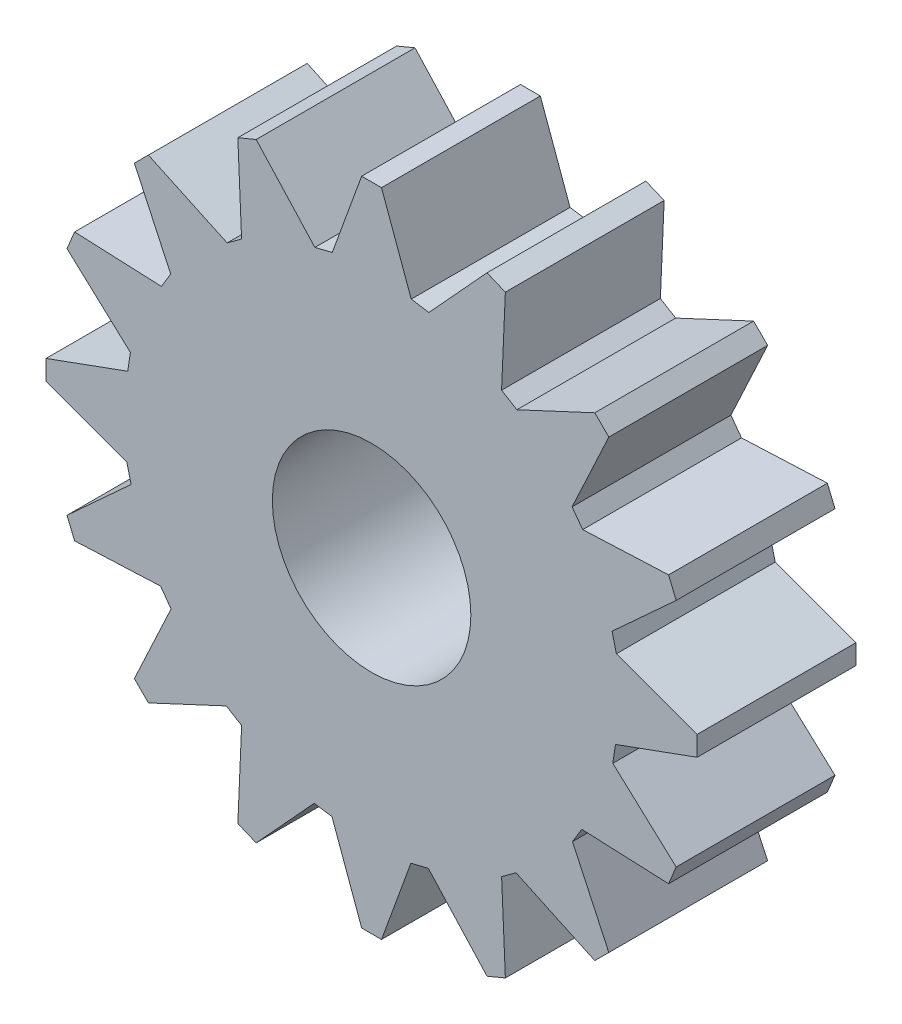
from build123d import *

# Parameters (mm, degrees)
SKETCH_1_R      = 2.5
EXTRUDE_1_DEPTH = 4


with BuildPart() as part:
    # 草图1 → 凸台-拉伸1 (new body)
    with BuildSketch(Plane.XY):
        Polygon((-0.25, 8.2), (0.25, 8.2), (0.998649517, 6.143102356), (1.444411986, 6.075310901), (2.907034262, 7.671483025), (3.368974029, 7.480141309), (3.273495344, 5.293319907), (3.659383499, 5.060102858), (5.62149891, 5.975052301), (5.975052301, 5.62149891), (5.049981179, 3.637677487), (5.317247046, 3.274540026), (7.480141309, 3.368974029), (7.671483025, 2.907034262), (6.057653158, 1.428231645), (6.165607931, 0.990458158), (8.2, 0.25), (8.2, -0.25), (6.143102356, -0.998649517), (6.075310901, -1.444411986), (7.671483025, -2.907034262), (7.480141309, -3.368974029), (5.293319907, -3.273495344), (5.060102858, -3.659383499), (5.975052301, -5.62149891), (5.62149891, -5.975052301), (3.637677487, -5.049981179), (3.274540026, -5.317247046), (3.368974029, -7.480141309), (2.907034262, -7.671483025), (1.428231645, -6.057653158), (0.990458158, -6.165607931), (0.25, -8.2), (-0.25, -8.2), (-0.998649517, -6.143102356), (-1.444411986, -6.075310901), (-2.907034262, -7.671483025), (-3.368974029, -7.480141309), (-3.273495344, -5.293319907), (-3.659383499, -5.060102858), (-5.62149891, -5.975052301), (-5.975052301, -5.62149891), (-5.049981179, -3.637677487), (-5.317247046, -3.274540026), (-7.480141309, -3.368974029), (-7.671483025, -2.907034262), (-6.057653158, -1.428231645), (-6.165607931, -0.990458158), (-8.2, -0.25), (-8.2, 0.25), (-6.143102356, 0.998649517), (-6.075310901, 1.444411986), (-7.671483025, 2.907034262), (-7.480141309, 3.368974029), (-5.293319907, 3.273495344), (-5.060102858, 3.659383499), (-5.975052301, 5.62149891), (-5.62149891, 5.975052301), (-3.637677487, 5.049981179), (-3.274540026, 5.317247046), (-3.368974029, 7.480141309), (-2.907034262, 7.671483025), (-1.428231645, 6.057653158), (-0.990458158, 6.165607931), align=None)
        Circle(SKETCH_1_R, mode=Mode.SUBTRACT)
    extrude(amount=EXTRUDE_1_DEPTH)


solid = part.part
